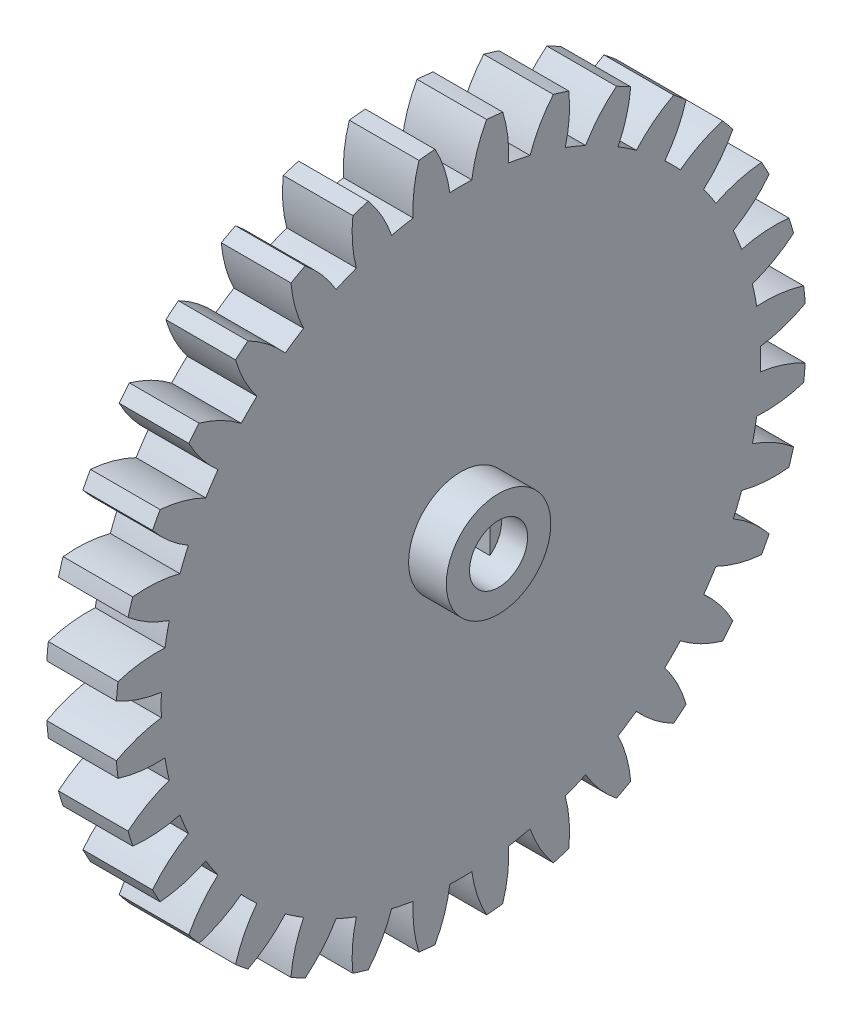
from build123d import *

# Parameters (mm, degrees)
BASPROSKE_W         = 6
BASPROSKE_H         = 29.75
TOOTHCUT_DEPTH      = 43.498529386
TEETHCUTS_COUNT     = 32
TEETHCUTS_ANGLE     = 348.75
BORSKE_R            = 0.4
BORE_DEPTH          = 50.0000508
SKETCH2_R           = 4.5
BOSS_EXTRUDE1_DEPTH = 3.25
SKETCH3_R           = 2.5
CUT_EXTRUDE1_DEPTH  = 2.25
CUT_EXTRUDE3_DEPTH  = 6


with BuildPart() as part:
    # BasProSke → Base-Revolve (revolve)
    with BuildSketch(Plane(origin=(0, 0, 0), x_dir=(1, 0, 0), z_dir=(0, 1, 0)), mode=Mode.PRIVATE) as base_revolve_sk:
        with Locations((3, 14.875)):
            Rectangle(BASPROSKE_W, BASPROSKE_H)
    revolve(base_revolve_sk.sketch.rotate(Axis((-10, 0, 0), (1, 0, 0)), 180), axis=Axis((-10, 0, 0), (1, 0, 0)))

    # TooCutSke → ToothCut (cut, through all)
    with BuildSketch(Plane(origin=(0, 0, 0), x_dir=(0, 0, -1), z_dir=(1, 0, 0))):
        with BuildLine():
            ThreePointArc((0.948063121, 25.794082821), (0, 25.8115), (-0.948063121, 25.794082821))
            ThreePointArc((-0.948063121, 25.794082821), (-1.412588604, 27.80222237), (-2.237243361, 29.691230815))
            ThreePointArc((-2.237243361, 29.691230815), (0, 29.7754), (2.237243361, 29.691230815))
            ThreePointArc((2.237243361, 29.691230815), (1.412588604, 27.80222237), (0.948063121, 25.794082821))
        make_face()
    toothcut = extrude(amount=TOOTHCUT_DEPTH, mode=Mode.SUBTRACT)

    # TeethCuts: ToothCut ×32 about axis
    teethcuts_axis = Axis((-10, 0, 0), (1, 0, 0))
    for i in range(1, TEETHCUTS_COUNT):
        add(toothcut.rotate(teethcuts_axis, i * TEETHCUTS_ANGLE / (TEETHCUTS_COUNT - 1)), mode=Mode.SUBTRACT)

    # BorSke → Bore (cut, symmetric)
    with BuildSketch(Plane(origin=(0, 0, 0), x_dir=(0, 0, -1), z_dir=(1, 0, 0))):
        with Locations(Location((0, 0, 0), (0, 0, 180))):
            Circle(BORSKE_R)
    extrude(amount=BORE_DEPTH, both=True, mode=Mode.SUBTRACT)

    # Sketch2 → Boss-Extrude1 (add)
    with BuildSketch(Plane(origin=(6, 0, 0), x_dir=(0, 0, -1), z_dir=(1, 0, 0))):
        with Locations(Location((0, 0, 0), (0, 0, 180))):
            Circle(SKETCH2_R)
    extrude(amount=BOSS_EXTRUDE1_DEPTH)

    # Sketch3 → Cut-Extrude1 (cut)
    with BuildSketch(Plane(origin=(9.25, 0, 0), x_dir=(0, 0, -1), z_dir=(1, 0, 0))):
        Circle(SKETCH3_R)
    extrude(amount=-CUT_EXTRUDE1_DEPTH, mode=Mode.SUBTRACT)

    # Sketch5 → Cut-Extrude3 (cut)
    with BuildSketch(Plane(origin=(7, 0, 0), x_dir=(0, 0, -1), z_dir=(1, 0, 0))):
        with BuildLine():
            ThreePointArc((1.500137399, 1.999896944), (0.000171753, 2.499999994), (-1.499862594, 2.000103047))
            Line((-1.499862594, 2.000103047), (-1.500137399, -1.999896944))
            ThreePointArc((-1.500137399, -1.999896944), (-0.000171753, -2.499999994), (1.499862594, -2.000103047))
            Line((1.499862594, -2.000103047), (1.500137399, 1.999896944))
        make_face()
    extrude(amount=-CUT_EXTRUDE3_DEPTH, mode=Mode.SUBTRACT)


solid = part.part
